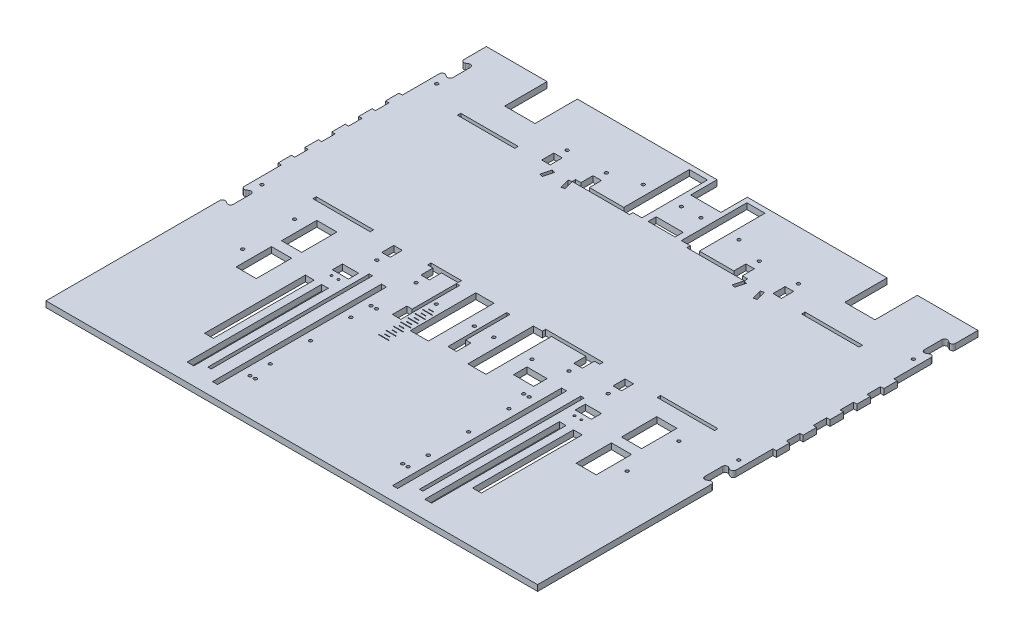
from build123d import *

# Parameters (mm, degrees)
SKETCH1_W                  = 54.186666667
SKETCH1_H                  = 3.175
SKETCH1_W_2                = 54.186666666
SKETCH1_W_3                = 3.175
SKETCH1_H_2                = 12.7
MAIN_EXTRUDE_DEPTH         = 5.588
SKETCH3_W                  = 25.484666667
SKETCH3_H                  = 3.175
UNDER_TROUGH_FILL_DEPTH    = 5.588
SKETCH4_R                  = 1.499997
SKETCH4_W                  = 12.7
SKETCH4_H                  = 3.175
SKETCH4_W_2                = 17.1
SKETCH4_H_2                = 61.9125
LEVER_HOLES_DEPTH          = 6.588
SKETCH5_W                  = 17.1
SKETCH5_H                  = 61.9125
SKETCH5_W_2                = 0.15
SKETCH5_H_2                = 3.175
SKETCH5_R                  = 1.5
TROUGH_SLOT_DEPTH          = 6.588
SKETCH6_R                  = 1.05
SKETCH6_W                  = 15.24
SKETCH6_H                  = 9.525
CLOSE_SWITCH_HOLES_DEPTH   = 6.588
SKETCH7_W                  = 9.525
SKETCH7_H                  = 0.508
SKETCH7_W_2                = 4.7625
TROUGH_MEASUREMENT_DEPTH   = 6.588
SKETCH8_W                  = 19.05
SKETCH8_H                  = 33.3375
SKETCH8_H_2                = 12.7
SKETCH8_W_2                = 28.575
SKETCH8_H_3                = 40
SKETCH8_W_3                = 25.4
SKETCH8_H_4                = 7.62
WIRE_HOLES_DEPTH           = 6.588
SKETCH9_R                  = 1.5
SKETCH9_W                  = 8
SKETCH9_H                  = 11.43
IR_SLOTS_DEPTH             = 6.588
DOOR_FLANGE_SLOTS_DEPTH    = 6.588
SKETCH12_R                 = 1.5
SKETCH12_W                 = 3.175
SKETCH12_H                 = 12.7
FLOOR_MOUNT_HOLES_DEPTH    = 6.588
EXTENSION_CENTER_CUT_DEPTH = 6.588
SKETCH13_W                 = 464.2612
SKETCH13_H                 = 114.3
CENTER_EXTEND_DEPTH        = 5.588
SKETCH15_W                 = 3.175
SKETCH15_H                 = 152.4
TRACK_CUTS_DEPTH           = 6.588
SKETCH18_R                 = 1.5
SKETCH18_W                 = 4.7752
SKETCH18_H                 = 159.639
SERVO_RACK_HOLES_DEPTH     = 6.588
SKETCH17_W                 = 8.255
SKETCH17_H                 = 95.25
SKETCH17_W_2               = 6.35
SKETCH17_H_2               = 127
SERVO_WIRE_CUTS_DEPTH      = 6.588
SKETCH19_R                 = 1.5
PI_MOUNT_HOLES_DEPTH       = 6.588
SKETCH20_R                 = 1.5
SKETCH20_W                 = 8
SKETCH20_H                 = 11.43
IR2_DEPTH                  = 5.588
SKETCH21_W                 = 15.089349107
SKETCH21_H                 = 5.588
BOSS_EXTRUDE1_DEPTH        = 28.575
SKETCH22_R                 = 1.499997
CUT_EXTRUDE1_DEPTH         = 6.588


with BuildPart() as part:
    # Sketch1 → Main Extrude (new body)
    with BuildSketch(Plane(origin=(0, 0, 0), x_dir=(1, 0, 0), z_dir=(0, 1, 0))):
        Polygon((406.4, 136.525), (-406.4, 136.525), (-406.4, 69.85), (-352.213333333, 69.85), (-352.213333333, 66.675), (-377.825, 66.675), (-377.825, 57.15), (-381, 57.15), (-381, 66.675), (-406.4, 66.675), (-406.4, -66.675), (-381, -66.675), (-381, -57.15), (-377.825, -57.15), (-377.825, -66.675), (-352.213333333, -66.675), (-352.213333333, -69.85), (-406.4, -69.85), (-406.4, -165.1), (406.4, -165.1), (406.4, -69.85), (352.213333333, -69.85), (352.213333333, -66.675), (377.825, -66.675), (377.825, -57.15), (381, -57.15), (381, -66.675), (406.4, -66.675), (406.4, 66.675), (381, 66.675), (381, 57.15), (377.825, 57.15), (377.825, 66.675), (352.213333333, 66.675), (352.213333333, 69.85), (406.4, 69.85), align=None)
        with Locations((270.933333334, -68.2625)):
            Rectangle(SKETCH1_W, SKETCH1_H, mode=Mode.SUBTRACT)
        with Locations((162.56, -68.2625)):
            Rectangle(SKETCH1_W_2, SKETCH1_H, mode=Mode.SUBTRACT)
        with Locations((54.186666667, -68.2625)):
            Rectangle(SKETCH1_W, SKETCH1_H, mode=Mode.SUBTRACT)
        with Locations((-54.186666667, -68.2625)):
            Rectangle(SKETCH1_W, SKETCH1_H, mode=Mode.SUBTRACT)
        with Locations((-162.56, -68.2625)):
            Rectangle(SKETCH1_W_2, SKETCH1_H, mode=Mode.SUBTRACT)
        with Locations((-270.933333334, -68.2625)):
            Rectangle(SKETCH1_W, SKETCH1_H, mode=Mode.SUBTRACT)
        with Locations((379.4125, -38.1)):
            Rectangle(SKETCH1_W_3, SKETCH1_H_2, mode=Mode.SUBTRACT)
        with Locations((379.4125, -12.7)):
            Rectangle(SKETCH1_W_3, SKETCH1_H_2, mode=Mode.SUBTRACT)
        with Locations((379.4125, 12.7)):
            Rectangle(SKETCH1_W_3, SKETCH1_H_2, mode=Mode.SUBTRACT)
        with Locations((379.4125, 38.1)):
            Rectangle(SKETCH1_W_3, SKETCH1_H_2, mode=Mode.SUBTRACT)
        with Locations((-379.4125, -38.1)):
            Rectangle(SKETCH1_W_3, SKETCH1_H_2, mode=Mode.SUBTRACT)
        with Locations((-379.4125, -12.7)):
            Rectangle(SKETCH1_W_3, SKETCH1_H_2, mode=Mode.SUBTRACT)
        with Locations((-379.4125, 12.7)):
            Rectangle(SKETCH1_W_3, SKETCH1_H_2, mode=Mode.SUBTRACT)
        with Locations((-379.4125, 38.1)):
            Rectangle(SKETCH1_W_3, SKETCH1_H_2, mode=Mode.SUBTRACT)
        with Locations((270.933333334, 68.2625)):
            Rectangle(SKETCH1_W, SKETCH1_H, mode=Mode.SUBTRACT)
        with Locations((162.56, 68.2625)):
            Rectangle(SKETCH1_W_2, SKETCH1_H, mode=Mode.SUBTRACT)
        with Locations((54.186666667, 68.2625)):
            Rectangle(SKETCH1_W, SKETCH1_H, mode=Mode.SUBTRACT)
        with Locations((-54.186666667, 68.2625)):
            Rectangle(SKETCH1_W, SKETCH1_H, mode=Mode.SUBTRACT)
        with Locations((-162.56, 68.2625)):
            Rectangle(SKETCH1_W_2, SKETCH1_H, mode=Mode.SUBTRACT)
        with Locations((-270.933333334, 68.2625)):
            Rectangle(SKETCH1_W, SKETCH1_H, mode=Mode.SUBTRACT)
    extrude(amount=MAIN_EXTRUDE_DEPTH)

    # Sketch3 → Under Trough Fill (add)
    with BuildSketch(Plane(origin=(0, 5.588, 0), x_dir=(1, 0, 0), z_dir=(0, 1, 0))):
        with Locations((-39.835666667, -68.2625)):
            Rectangle(SKETCH3_W, SKETCH3_H)
    extrude(amount=-UNDER_TROUGH_FILL_DEPTH)

    # Sketch4 → Lever Holes (cut, through all)
    with BuildSketch(Plane(origin=(0, 5.588, 0), x_dir=(1, 0, 0), z_dir=(0, 1, 0))):
        with Locations((9.178, -97.7625)):
            Circle(SKETCH4_R)
        with Locations((45.178, -97.7625)):
            Circle(SKETCH4_R)
        with Locations((9.178, 97.7625)):
            Circle(SKETCH4_R)
        with Locations((45.178, 97.7625)):
            Circle(SKETCH4_R)
        with Locations((-9.178, 97.7625)):
            Circle(SKETCH4_R)
        with Locations((-45.178, 97.7625)):
            Circle(SKETCH4_R)
        with Locations((-393.7, -65.0875)):
            Rectangle(SKETCH4_W, SKETCH4_H)
        with Locations((-393.7, 65.0875)):
            Rectangle(SKETCH4_W, SKETCH4_H)
        with Locations((393.7, 65.0875)):
            Rectangle(SKETCH4_W, SKETCH4_H)
        with Locations((393.7, -65.0875)):
            Rectangle(SKETCH4_W, SKETCH4_H)
        with Locations((27.178, -100.80625)):
            Rectangle(SKETCH4_W_2, SKETCH4_H_2)
        with Locations((27.178, 100.80625)):
            Rectangle(SKETCH4_W_2, SKETCH4_H_2)
        with Locations((-27.178, 100.80625)):
            Rectangle(SKETCH4_W_2, SKETCH4_H_2)
    extrude(amount=-LEVER_HOLES_DEPTH, mode=Mode.SUBTRACT)

    # Sketch5 → Trough Slot (cut, through all)
    with BuildSketch(Plane(origin=(0, 5.588, 0), x_dir=(1, 0, 0), z_dir=(0, 1, 0))):
        Polygon((-52.428, -71.4248), (-52.428, -113.3), (-57.428, -113.3), (-57.428, -127), (-49.428, -127), (-49.428, -71.4248), align=None)
        Polygon((-4.928, -71.4248), (-4.928, -127), (3.072, -127), (3.072, -113.3), (-1.928, -113.3), (-1.928, -71.4248), align=None)
        with Locations((-27.178, -100.80625)):
            Rectangle(SKETCH5_W, SKETCH5_H)
        with Locations((-52.503, -68.2625)):
            Rectangle(SKETCH5_W_2, SKETCH5_H_2)
        with Locations((-9.178, -97.7625)):
            Circle(SKETCH5_R)
        with Locations((-45.178, -97.7625)):
            Circle(SKETCH5_R)
    extrude(amount=-TROUGH_SLOT_DEPTH, mode=Mode.SUBTRACT)

    # Sketch6 → Close Switch Holes (cut, through all)
    with BuildSketch(Plane(origin=(0, 5.588, 0), x_dir=(1, 0, 0), z_dir=(0, 1, 0))):
        with Locations((117.9405058, -123.8499876)):
            Circle(SKETCH6_R)
        with Locations((111.4404934, -123.8499876)):
            Circle(SKETCH6_R)
        with Locations((-117.9405058, -123.8499876)):
            Circle(SKETCH6_R)
        with Locations((-111.4404934, -123.8499876)):
            Circle(SKETCH6_R)
        with Locations((-114.6904996, -114.0074876)):
            Rectangle(SKETCH6_W, SKETCH6_H)
        with Locations((114.6904996, -114.0074876)):
            Rectangle(SKETCH6_W, SKETCH6_H)
    extrude(amount=-CLOSE_SWITCH_HOLES_DEPTH, mode=Mode.SUBTRACT)

    # Sketch7 → Trough Measurement (cut, through all)
    with BuildSketch(Plane(origin=(0, 5.588, 0), x_dir=(1, 0, 0), z_dir=(0, 1, 0))):
        with Locations((-42.578, -142.992)):
            Rectangle(SKETCH7_W, SKETCH7_H)
        with Locations((-42.578, -149.85)):
            Rectangle(SKETCH7_W, SKETCH7_H)
        with Locations((-42.578, -146.675)):
            Rectangle(SKETCH7_W_2, SKETCH7_H)
        with Locations((-42.578, -139.817)):
            Rectangle(SKETCH7_W_2, SKETCH7_H)
        with Locations((-42.578, -136.134)):
            Rectangle(SKETCH7_W, SKETCH7_H)
        with Locations((-42.578, -132.959)):
            Rectangle(SKETCH7_W_2, SKETCH7_H)
        with Locations((-42.578, -129.276)):
            Rectangle(SKETCH7_W, SKETCH7_H)
        with Locations((-42.578, -126.101)):
            Rectangle(SKETCH7_W_2, SKETCH7_H)
        with Locations((-42.578, -122.418)):
            Rectangle(SKETCH7_W, SKETCH7_H)
        with Locations((-42.578, -119.243)):
            Rectangle(SKETCH7_W_2, SKETCH7_H)
        with Locations((-42.578, -115.56)):
            Rectangle(SKETCH7_W, SKETCH7_H)
        with Locations((-42.578, -112.385)):
            Rectangle(SKETCH7_W_2, SKETCH7_H)
        with Locations((-42.578, -108.702)):
            Rectangle(SKETCH7_W, SKETCH7_H)
        with Locations((-42.578, -105.527)):
            Rectangle(SKETCH7_W_2, SKETCH7_H)
    extrude(amount=-TROUGH_MEASUREMENT_DEPTH, mode=Mode.SUBTRACT)

    # Sketch8 → Wire Holes (cut, through all)
    with BuildSketch(Plane(origin=(0, 5.588, 0), x_dir=(1, 0, 0), z_dir=(0, 1, 0))):
        with Locations((-160.528, -145.25625)):
            Rectangle(SKETCH8_W, SKETCH8_H)
        with Locations((-160.528, -102.39375)):
            Rectangle(SKETCH8_W, SKETCH8_H)
        with Locations((160.528, -145.25625)):
            Rectangle(SKETCH8_W, SKETCH8_H)
        with Locations((160.528, -102.39375)):
            Rectangle(SKETCH8_W, SKETCH8_H)
        with Locations((58.588, -112.7125)):
            Rectangle(SKETCH8_W, SKETCH8_H_2)
        with Locations((0, 116.525)):
            Rectangle(SKETCH8_W_2, SKETCH8_H_3)
        with Locations((0, 73.66)):
            Rectangle(SKETCH8_W_3, SKETCH8_H_4)
        with Locations((-160.528, 116.525)):
            Rectangle(SKETCH8_W_2, SKETCH8_H_3)
        with Locations((160.528, 116.525)):
            Rectangle(SKETCH8_W_2, SKETCH8_H_3)
    extrude(amount=-WIRE_HOLES_DEPTH, mode=Mode.SUBTRACT)

    # Sketch9 → IR Slots (cut, through all)
    with BuildSketch(Plane(origin=(0, 5.588, 0), x_dir=(1, 0, 0), z_dir=(0, 1, 0))):
        with Locations((109.2096114, -89.85)):
            Circle(SKETCH9_R)
        with Locations((-109.2096114, -89.85)):
            Circle(SKETCH9_R)
        with Locations((109.2096114, 89.85)):
            Circle(SKETCH9_R)
        with Locations((-109.2096114, 89.85)):
            Circle(SKETCH9_R)
        with Locations((-109.2096114, 75.565)):
            Rectangle(SKETCH9_W, SKETCH9_H)
        with Locations((109.2096114, 75.565)):
            Rectangle(SKETCH9_W, SKETCH9_H)
        with Locations((109.2096114, -75.565)):
            Rectangle(SKETCH9_W, SKETCH9_H)
        with Locations((-109.2096114, -75.565)):
            Rectangle(SKETCH9_W, SKETCH9_H)
    extrude(amount=-IR_SLOTS_DEPTH, mode=Mode.SUBTRACT)

    # Sketch10 → Door Flange Slots (cut, through all)
    with BuildSketch(Plane(origin=(0, 5.588, 0), x_dir=(1, 0, 0), z_dir=(0, 1, 0))):
        Polygon((-100.061001873, 66.675), (-96.994187374, 65.853249532), (-99.459438779, 56.652806036), (-102.526253277, 57.474556505), align=None)
        Polygon((-84.361812626, 65.853249532), (-81.294998127, 66.675), (-78.829746723, 57.474556505), (-81.896561221, 56.652806036), align=None)
        Polygon((81.294998127, 66.675), (78.829746723, 57.474556505), (81.896561221, 56.652806036), (84.361812626, 65.853249532), align=None)
        Polygon((96.994187374, 65.853249532), (99.459438779, 56.652806036), (102.526253277, 57.474556505), (100.061001873, 66.675), align=None)
    extrude(amount=-DOOR_FLANGE_SLOTS_DEPTH, mode=Mode.SUBTRACT)

    # Sketch12 → Floor Mount Holes (cut, through all)
    with BuildSketch(Plane(origin=(0, 5.588, 0), x_dir=(1, 0, 0), z_dir=(0, 1, 0))):
        with Locations((-253.58725, -82.55)):
            Circle(SKETCH12_R)
        with Locations((-225.13925, -82.55)):
            Circle(SKETCH12_R)
        with Locations((-253.58725, 82.55)):
            Circle(SKETCH12_R)
        with Locations((-225.13925, 82.55)):
            Circle(SKETCH12_R)
        with Locations((225.13925, 82.55)):
            Circle(SKETCH12_R)
        with Locations((253.58725, 82.55)):
            Circle(SKETCH12_R)
        with Locations((225.13925, -82.55)):
            Circle(SKETCH12_R)
        with Locations((253.58725, -82.55)):
            Circle(SKETCH12_R)
        with Locations((-239.36325, -82.55)):
            Rectangle(SKETCH12_W, SKETCH12_H)
        with Locations((-239.36325, 82.55)):
            Rectangle(SKETCH12_W, SKETCH12_H)
        with Locations((239.36325, 82.55)):
            Rectangle(SKETCH12_W, SKETCH12_H)
        with Locations((239.36325, -82.55)):
            Rectangle(SKETCH12_W, SKETCH12_H)
    extrude(amount=-FLOOR_MOUNT_HOLES_DEPTH, mode=Mode.SUBTRACT)

    # Sketch11_3 → Extension Center Cut (cut, through all)
    with BuildSketch(Plane(origin=(0, 5.588, 0), x_dir=(1, 0, 0), z_dir=(0, 1, 0))):
        with BuildLine():
            Line((-232.1306, 57.15), (-232.1306, 92.075))
            ThreePointArc((-232.1306, 92.075), (-230.8606, 94.274704526), (-228.3206, 94.274704526))
            Line((-228.3206, 94.274704526), (-226.4156, 93.174852263))
            ThreePointArc((-226.4156, 93.174852263), (-223.8756, 93.174852263), (-222.6056, 95.374556788))
            Line((-222.6056, 95.374556788), (-222.6056, 111.975738686))
            ThreePointArc((-222.6056, 111.975738686), (-223.8756, 114.175443212), (-226.4156, 114.175443212))
            Line((-226.4156, 114.175443212), (-228.3206, 113.075590949))
            ThreePointArc((-228.3206, 113.075590949), (-230.8606, 113.075590949), (-232.1306, 115.275295474))
            Line((-232.1306, 115.275295474), (-232.1306, 136.525))
            Line((-232.1306, 136.525), (-406.4, 136.525))
            Line((-406.4, 136.525), (-406.4, -165.1))
            Line((-406.4, -165.1), (-232.1306, -165.1))
            Line((-232.1306, -165.1), (-232.1306, -115.275295474))
            ThreePointArc((-232.1306, -115.275295474), (-230.8606, -113.075590949), (-228.3206, -113.075590949))
            Line((-228.3206, -113.075590949), (-226.4156, -114.175443212))
            ThreePointArc((-226.4156, -114.175443212), (-223.8756, -114.175443212), (-222.6056, -111.975738686))
            Line((-222.6056, -111.975738686), (-222.6056, -95.374556788))
            ThreePointArc((-222.6056, -95.374556788), (-223.8756, -93.174852263), (-226.4156, -93.174852263))
            Line((-226.4156, -93.174852263), (-228.3206, -94.274704526))
            ThreePointArc((-228.3206, -94.274704526), (-230.8606, -94.274704526), (-232.1306, -92.075))
            Line((-232.1306, -92.075), (-232.1306, -57.15))
            Line((-232.1306, -57.15), (-235.3056, -57.15))
            Line((-235.3056, -57.15), (-235.3056, -44.45))
            Line((-235.3056, -44.45), (-232.1306, -44.45))
            Line((-232.1306, -44.45), (-232.1306, -31.75))
            Line((-232.1306, -31.75), (-235.3056, -31.75))
            Line((-235.3056, -31.75), (-235.3056, -19.05))
            Line((-235.3056, -19.05), (-232.1306, -19.05))
            Line((-232.1306, -19.05), (-232.1306, -6.35))
            Line((-232.1306, -6.35), (-235.3056, -6.35))
            Line((-235.3056, -6.35), (-235.3056, 6.35))
            Line((-235.3056, 6.35), (-232.1306, 6.35))
            Line((-232.1306, 6.35), (-232.1306, 19.05))
            Line((-232.1306, 19.05), (-235.3056, 19.05))
            Line((-235.3056, 19.05), (-235.3056, 31.75))
            Line((-235.3056, 31.75), (-232.1306, 31.75))
            Line((-232.1306, 31.75), (-232.1306, 44.45))
            Line((-232.1306, 44.45), (-235.3056, 44.45))
            Line((-235.3056, 44.45), (-235.3056, 57.15))
            Line((-235.3056, 57.15), (-232.1306, 57.15))
        make_face()
        with BuildLine():
            Line((406.4, 136.525), (232.1306, 136.525))
            Line((232.1306, 136.525), (232.1306, 115.275295474))
            ThreePointArc((232.1306, 115.275295474), (230.8606, 113.075590949), (228.3206, 113.075590949))
            Line((228.3206, 113.075590949), (226.4156, 114.175443212))
            ThreePointArc((226.4156, 114.175443212), (223.8756, 114.175443212), (222.6056, 111.975738686))
            Line((222.6056, 111.975738686), (222.6056, 95.374556788))
            ThreePointArc((222.6056, 95.374556788), (223.8756, 93.174852263), (226.4156, 93.174852263))
            Line((226.4156, 93.174852263), (228.3206, 94.274704526))
            ThreePointArc((228.3206, 94.274704526), (230.8606, 94.274704526), (232.1306, 92.075))
            Line((232.1306, 92.075), (232.1306, 57.15))
            Line((232.1306, 57.15), (235.3056, 57.15))
            Line((235.3056, 57.15), (235.3056, 44.45))
            Line((235.3056, 44.45), (232.1306, 44.45))
            Line((232.1306, 44.45), (232.1306, 31.75))
            Line((232.1306, 31.75), (235.3056, 31.75))
            Line((235.3056, 31.75), (235.3056, 19.05))
            Line((235.3056, 19.05), (232.1306, 19.05))
            Line((232.1306, 19.05), (232.1306, 6.35))
            Line((232.1306, 6.35), (235.3056, 6.35))
            Line((235.3056, 6.35), (235.3056, -6.35))
            Line((235.3056, -6.35), (232.1306, -6.35))
            Line((232.1306, -6.35), (232.1306, -19.05))
            Line((232.1306, -19.05), (235.3056, -19.05))
            Line((235.3056, -19.05), (235.3056, -31.75))
            Line((235.3056, -31.75), (232.1306, -31.75))
            Line((232.1306, -31.75), (232.1306, -44.45))
            Line((232.1306, -44.45), (235.3056, -44.45))
            Line((235.3056, -44.45), (235.3056, -57.15))
            Line((235.3056, -57.15), (232.1306, -57.15))
            Line((232.1306, -57.15), (232.1306, -92.075))
            ThreePointArc((232.1306, -92.075), (230.8606, -94.274704526), (228.3206, -94.274704526))
            Line((228.3206, -94.274704526), (226.4156, -93.174852263))
            ThreePointArc((226.4156, -93.174852263), (223.8756, -93.174852263), (222.6056, -95.374556788))
            Line((222.6056, -95.374556788), (222.6056, -111.975738686))
            ThreePointArc((222.6056, -111.975738686), (223.8756, -114.175443212), (226.4156, -114.175443212))
            Line((226.4156, -114.175443212), (228.3206, -113.075590949))
            ThreePointArc((228.3206, -113.075590949), (230.8606, -113.075590949), (232.1306, -115.275295474))
            Line((232.1306, -115.275295474), (232.1306, -165.1))
            Line((232.1306, -165.1), (406.4, -165.1))
            Line((406.4, -165.1), (406.4, 136.525))
        make_face()
    extrude(amount=-EXTENSION_CENTER_CUT_DEPTH, mode=Mode.SUBTRACT)

    # Sketch13 → Center Extend (add)
    with BuildSketch(Plane(origin=(0, 5.588, 0), x_dir=(1, 0, 0), z_dir=(0, 1, 0))):
        with Locations((0, -222.25)):
            Rectangle(SKETCH13_W, SKETCH13_H)
    extrude(amount=-CENTER_EXTEND_DEPTH)

    # Sketch15 → Track Cuts (cut, through all)
    with BuildSketch(Plane(origin=(0, 5.588, 0), x_dir=(1, 0, 0), z_dir=(0, 1, 0))):
        with Locations((99.928, -180.975)):
            Rectangle(SKETCH15_W, SKETCH15_H)
        with Locations((-99.928, -180.975)):
            Rectangle(SKETCH15_W, SKETCH15_H)
    extrude(amount=-TRACK_CUTS_DEPTH, mode=Mode.SUBTRACT)

    # Sketch18 → Servo Rack Holes (cut, through all)
    with BuildSketch(Plane(origin=(0, 5.588, 0), x_dir=(1, 0, 0), z_dir=(0, 1, 0))):
        with Locations((-69.6103, -129.921)):
            Circle(SKETCH18_R)
        with Locations((-69.6103, -244.221)):
            Circle(SKETCH18_R)
        with Locations((-74.63315, -187.071)):
            Circle(SKETCH18_R)
        with Locations((74.63315, -187.071)):
            Circle(SKETCH18_R)
        with Locations((69.6103, -244.221)):
            Circle(SKETCH18_R)
        with Locations((69.6103, -129.921)):
            Circle(SKETCH18_R)
        with Locations((-74.63315, -225.171)):
            Circle(SKETCH18_R)
        with Locations((-74.63315, -148.971)):
            Circle(SKETCH18_R)
        with Locations((74.63315, -225.171)):
            Circle(SKETCH18_R)
        with Locations((74.63315, -148.971)):
            Circle(SKETCH18_R)
        with Locations((-74.63315, -244.221)):
            Circle(SKETCH18_R)
        with Locations((-74.63315, -129.921)):
            Circle(SKETCH18_R)
        with Locations((74.63315, -244.221)):
            Circle(SKETCH18_R)
        with Locations((74.63315, -129.921)):
            Circle(SKETCH18_R)
        with Locations((-85.0154, -187.071)):
            Rectangle(SKETCH18_W, SKETCH18_H)
        with Locations((85.0154, -187.071)):
            Rectangle(SKETCH18_W, SKETCH18_H)
    extrude(amount=-SERVO_RACK_HOLES_DEPTH, mode=Mode.SUBTRACT)

    # Sketch17 → Servo Wire Cuts (cut, through all)
    with BuildSketch(Plane(origin=(0, 5.588, 0), x_dir=(1, 0, 0), z_dir=(0, 1, 0))):
        with Locations((126.5555, -183.4515)):
            Rectangle(SKETCH17_W, SKETCH17_H)
        with Locations((112.268, -199.3265)):
            Rectangle(SKETCH17_W_2, SKETCH17_H_2)
        with Locations((-126.5555, -183.4515)):
            Rectangle(SKETCH17_W, SKETCH17_H)
        with Locations((-112.268, -199.3265)):
            Rectangle(SKETCH17_W_2, SKETCH17_H_2)
    extrude(amount=-SERVO_WIRE_CUTS_DEPTH, mode=Mode.SUBTRACT)

    # Sketch19 → Pi Mount Holes (cut, through all)
    with BuildSketch(Plane(origin=(0, 5.588, 0), x_dir=(1, 0, 0), z_dir=(0, 1, 0))):
        with Locations((181.483, -95.25)):
            Circle(SKETCH19_R)
        with Locations((239.483, -95.25)):
            Circle(SKETCH19_R)
        with Locations((239.483, -144.25)):
            Circle(SKETCH19_R)
        with Locations((181.483, -144.25)):
            Circle(SKETCH19_R)
        with Locations((-239.483, -144.25)):
            Circle(SKETCH19_R)
        with Locations((-239.483, -95.25)):
            Circle(SKETCH19_R)
        with Locations((-181.483, -144.25)):
            Circle(SKETCH19_R)
        with Locations((-181.483, -95.25)):
            Circle(SKETCH19_R)
    extrude(amount=-PI_MOUNT_HOLES_DEPTH, mode=Mode.SUBTRACT)

    # Sketch20 → IR2 (cut)
    with BuildSketch(Plane(origin=(0, 5.588, 0), x_dir=(1, 0, 0), z_dir=(0, 1, 0))):
        with Locations((-72.2096114, -89.85)):
            Circle(SKETCH20_R)
        with Locations((-72.2096114, 89.85)):
            Circle(SKETCH20_R)
        with Locations((72.2096114, -89.85)):
            Circle(SKETCH20_R)
        with Locations((72.2096114, 89.85)):
            Circle(SKETCH20_R)
        with Locations((-72.2096114, -75.565)):
            Rectangle(SKETCH20_W, SKETCH20_H)
        with Locations((-72.2096114, 75.565)):
            Rectangle(SKETCH20_W, SKETCH20_H)
        with Locations((72.2096114, -75.565)):
            Rectangle(SKETCH20_W, SKETCH20_H)
        with Locations((72.2096114, 75.565)):
            Rectangle(SKETCH20_W, SKETCH20_H)
    extrude(amount=-IR2_DEPTH, mode=Mode.SUBTRACT)

    # Sketch21 → Boss-Extrude1 (add)
    with BuildSketch(Plane(origin=(-14.2875, 0, 0), x_dir=(0, 0, -1), z_dir=(1, 0, 0))):
        with Locations((104.069674554, 2.794)):
            Rectangle(SKETCH21_W, SKETCH21_H)
    extrude(amount=BOSS_EXTRUDE1_DEPTH)

    # Sketch22 → Cut-Extrude1 (cut, through all)
    with BuildSketch(Plane(origin=(0, 5.588, 0), x_dir=(1, 0, 0), z_dir=(0, 1, 0))):
        with Locations((-9.178, 97.7625)):
            Circle(SKETCH22_R)
        with Locations((9.178, 97.7625)):
            Circle(SKETCH22_R)
    extrude(amount=-CUT_EXTRUDE1_DEPTH, mode=Mode.SUBTRACT)


solid = part.part
